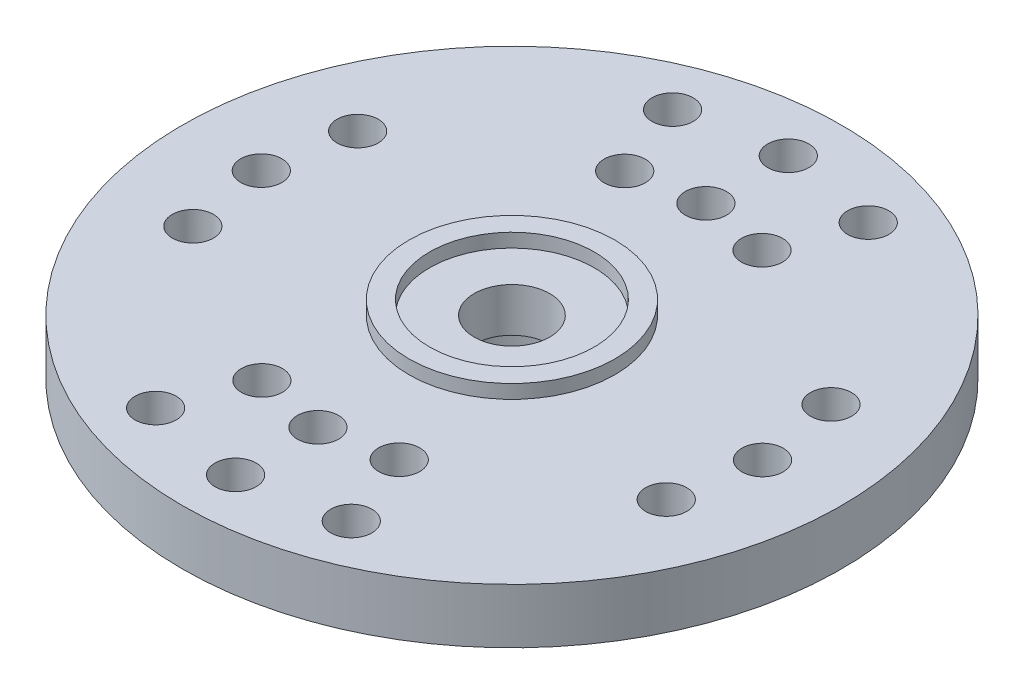
from build123d import *

# Parameters (mm, degrees)
SKETCH1_W                      = 12
SKETCH1_H                      = 2
SKETCH2_R                      = 4.45
BOSS_EXTRUDE1_DEPTH            = 2.6
SKETCH3_R                      = 3.75
BOSS_EXTRUDE2_DEPTH            = 0.5
F_1_5_1_5_DIAMETER_HOLE1_D     = 1.5
F_1_5_1_5_DIAMETER_HOLE1_DEPTH = 2.5


with BuildPart() as part:
    # Sketch1 → Revolve1 (revolve)
    with BuildSketch(Plane(origin=(0, 0, 0), x_dir=(-1, 0, 0), z_dir=(0, 0, -1))):
        with Locations((-6, 1)):
            Rectangle(SKETCH1_W, SKETCH1_H)
    revolve(axis=Axis((0, 0, 0), (0, 1, 0)))

    # Sketch2 → Boss-Extrude1 (add)
    with BuildSketch(Plane.XZ):
        Circle(SKETCH2_R)
    extrude(amount=BOSS_EXTRUDE1_DEPTH)

    # Sketch3 → Boss-Extrude2 (add)
    with BuildSketch(Plane(origin=(0, 2, 0), x_dir=(-1, 0, 0), z_dir=(0, 1, 0))):
        Circle(SKETCH3_R)
    extrude(amount=BOSS_EXTRUDE2_DEPTH)

    # Sketch4 → Cut-Revolve1 (revolve, cut)
    with BuildSketch(Plane(origin=(0, 0, 0), x_dir=(-1, 0, 0), z_dir=(0, 0, -1))):
        Polygon((-2.85, -2.6), (0, -2.6), (0, 2.5), (-3, 2.5), (-3, 2), (-1.375, 2), (-1.375, 0.4), (-2.85, 0.4), align=None)
    revolve(axis=Axis((0, -2.6, 0), (0, 1, 0)), mode=Mode.SUBTRACT)

    # Ø1.5 (1.5) Diameter Hole1
    with Locations(Plane(origin=(0, 0, 0), x_dir=(-1, 0, 0), z_dir=(0, -1, 0))):
        with Locations((-9.125, 0), (9.125, 0), (-8.617750577, -3), (-8.617750577, 3), (8.617750577, -3), (8.617750577, 3), (0, 7.0625), (0, -7.0625), (-2.5, 6.605218108), (2.5, 6.605218108), (-2.5, -6.605218108), (2.5, -6.605218108), (0, 10.0625), (0, -10.0625), (-3.561946903, 9.410974472), (3.561946903, 9.410974472), (-3.561946903, -9.410974472), (3.561946903, -9.410974472)):
            Hole(F_1_5_1_5_DIAMETER_HOLE1_D / 2, depth=F_1_5_1_5_DIAMETER_HOLE1_DEPTH)


solid = part.part
